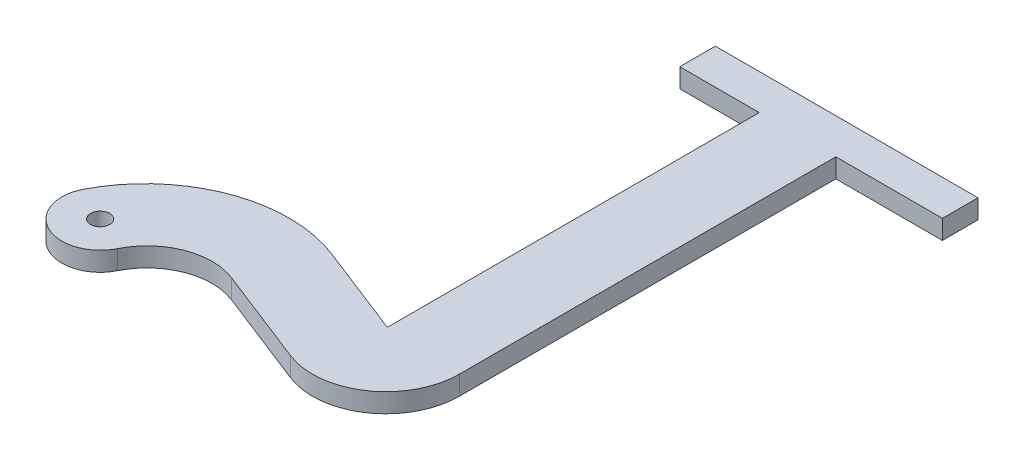
from build123d import *

# Parameters (mm, degrees)
ESQUISSE1_R        = 2.5
BOSS_EXTRU_1_DEPTH = 5


with BuildPart() as part:
    # Esquisse1 → Boss.-Extru.1 (new body)
    with BuildSketch(Plane(origin=(0, 0, 0), x_dir=(1, 0, 0), z_dir=(0, 1, 0))):
        with BuildLine():
            Line((30.416462038, 3.875687745), (55.823272708, -6.059403674))
            ThreePointArc((55.823272708, -6.059403674), (73.630583756, -4.03622534), (82, 11.811375395))
            Line((82, 11.811375395), (82, 110.123102525))
            Line((82, 110.123102525), (109.832159843, 110.123102525))
            Line((109.832159843, 110.123102525), (109.832159843, 119.415014129))
            Line((109.832159843, 119.415014129), (41.252434476, 119.415014129))
            Line((41.252434476, 119.415014129), (41.252434476, 110.123102525))
            Line((41.252434476, 110.123102525), (62, 110.123102525))
            Line((62, 110.123102525), (62, 13))
            Line((62, 13), (38.173084143, 22.317288594))
            ThreePointArc((38.173084143, 22.317288594), (11.245695012, 22.487512145), (-8.882082163, 4.599363906))
            ThreePointArc((-8.882082163, 4.599363906), (-4.515728742, -8.924893603), (8.966917542, -4.431695127))
            ThreePointArc((8.966917542, -4.431695127), (18.075204101, 3.89573938), (30.416462038, 3.875687745))
        make_face()
        Circle(ESQUISSE1_R, mode=Mode.SUBTRACT)
    extrude(amount=BOSS_EXTRU_1_DEPTH)


solid = part.part
